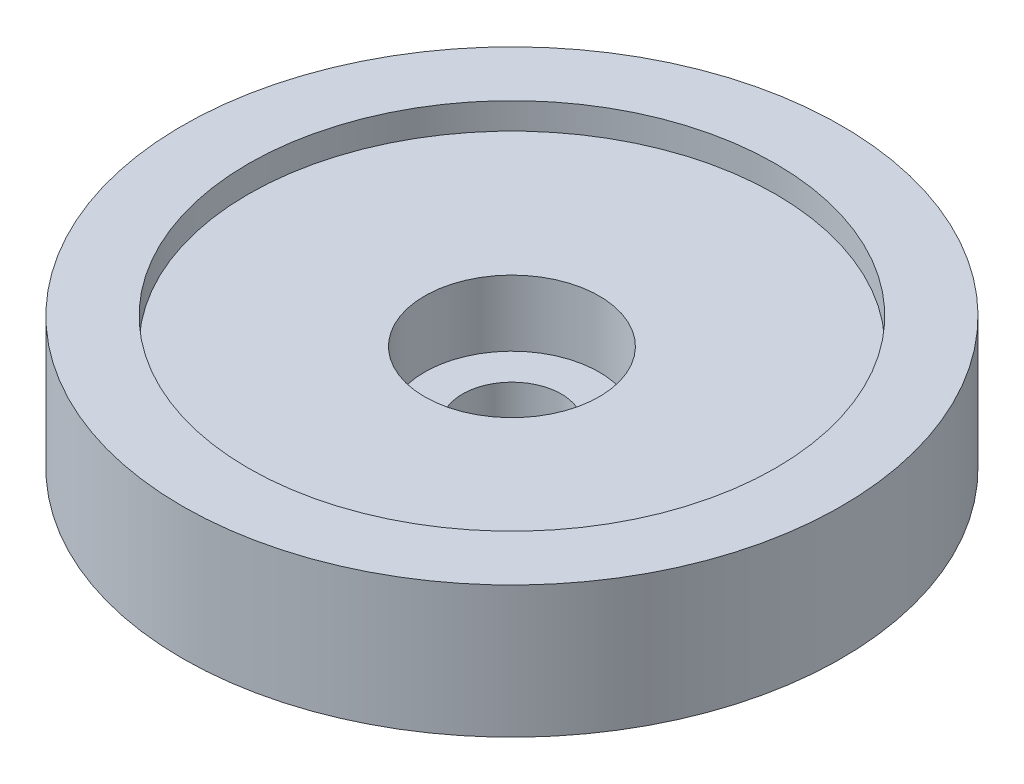
from build123d import *

# Parameters (mm, degrees)
SKETCH1_R               = 25
BOSS_EXTRUDE1_DEPTH     = 10
SKETCH2_R               = 20
CUT_EXTRUDE1_DEPTH      = 2
SKETCH3_R               = 6.625
CUT_EXTRUDE2_DEPTH      = 5
SKETCH4_R               = 3.75
CUT_EXTRUDE4_DEPTH      = 8
CUT_EXTRUDE4_DEPTH_BACK = 4


with BuildPart() as part:
    # Sketch1 → Boss-Extrude1 (new body)
    with BuildSketch(Plane(origin=(0, 0, 0), x_dir=(1, 0, 0), z_dir=(0, 1, 0))):
        Circle(SKETCH1_R)
    extrude(amount=BOSS_EXTRUDE1_DEPTH)

    # Sketch2 → Cut-Extrude1 (cut)
    with BuildSketch(Plane(origin=(0, 10, 0), x_dir=(1, 0, 0), z_dir=(0, 1, 0))):
        Circle(SKETCH2_R)
    extrude(amount=-CUT_EXTRUDE1_DEPTH, mode=Mode.SUBTRACT)

    # Sketch3 → Cut-Extrude2 (cut)
    with BuildSketch(Plane(origin=(0, 8, 0), x_dir=(1, 0, 0), z_dir=(0, 1, 0))):
        Circle(SKETCH3_R)
    extrude(amount=-CUT_EXTRUDE2_DEPTH, mode=Mode.SUBTRACT)

    # Sketch4 → Cut-Extrude4 (cut, two sides)
    with BuildSketch(Plane(origin=(0, 3, 0), x_dir=(1, 0, 0), z_dir=(0, 1, 0))) as cut_extrude4_sk:
        Circle(SKETCH4_R)
    extrude(amount=CUT_EXTRUDE4_DEPTH, mode=Mode.SUBTRACT)
    extrude(cut_extrude4_sk.sketch, amount=-CUT_EXTRUDE4_DEPTH_BACK, mode=Mode.SUBTRACT)


solid = part.part
